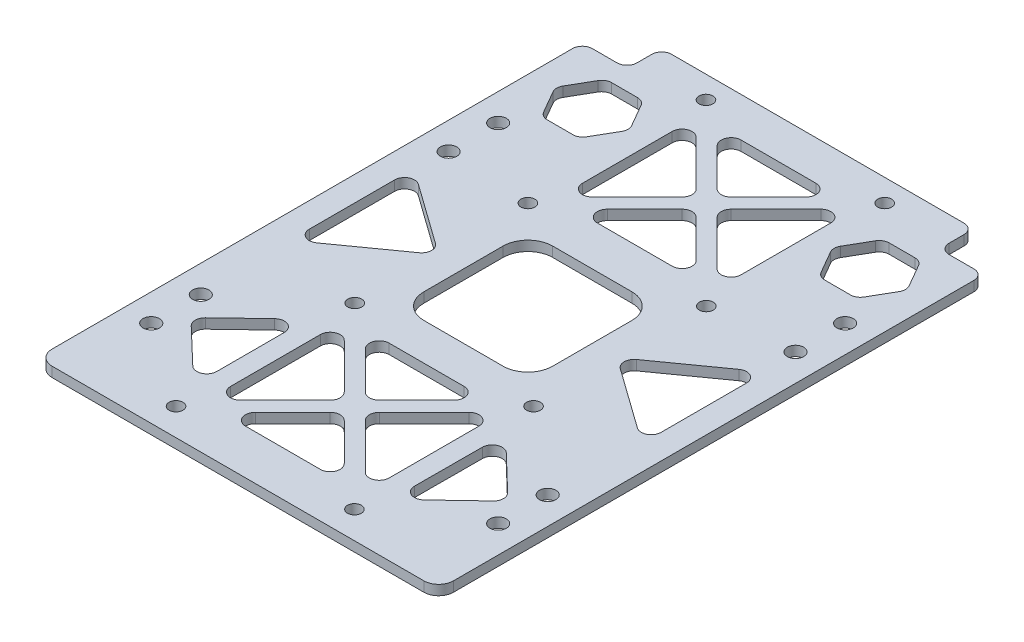
from build123d import *

# Parameters (mm, degrees)
SKETCH_1_W             = 81
SKETCH_1_H             = 117
EXTRUDE_1_DEPTH        = 2
FILLET_2_R             = 3
SKETCH_2_R             = 1.4
SKETCH_2_R_2           = 1.65
CUT_EXTRUDE_1_DEPTH    = 10
CUT_EXTRUDE_2_DEPTH    = 10
FILLET_3_R             = 2
CUT_EXTRUDE_3_DEPTH    = 10
FILLET_4_R             = 2
SKETCH_6_W             = 26
SKETCH_6_H             = 26
CUT_EXTRUDE_4_DEPTH    = 10
FILLET_5_R             = 5
CUT_EXTRUDE_5_DEPTH    = 10
FILLET_6_R             = 2
FILLET_6_OF_MIRROR_1_R = 2
CUT_EXTRUDE_6_DEPTH    = 10
CUT_EXTRUDE_7_DEPTH    = 10
FILLET_7_R             = 2


with BuildPart() as part:
    # 草图1 → 凸台-拉伸1 (new body)
    with BuildSketch(Plane(origin=(0, 0, 0), x_dir=(1, 0, 0), z_dir=(0, 1, 0))):
        Rectangle(SKETCH_1_W, SKETCH_1_H)
    extrude(amount=EXTRUDE_1_DEPTH)

    # 圆角2
    fillet_2_edges = [part.edges().sort_by_distance(p)[0] for p in [
        (40.5, 1, 58.5),
        (-40.5, 1, 58.5),
        (-40.5, 1, -58.5),
        (40.5, 1, -58.5),
    ]]
    fillet(fillet_2_edges, radius=FILLET_2_R)

    # 草图2 → 切除-拉伸1 (cut)
    with BuildSketch(Plane.XZ):
        with Locations((-18.000036, 16.931963864)):
            Circle(SKETCH_2_R)
        with Locations((18.068036136, 16.931963864)):
            Circle(SKETCH_2_R)
        with Locations((-18.000036, 53.000036)):
            Circle(SKETCH_2_R)
        with Locations((17.999928, 52.999964)):
            Circle(SKETCH_2_R)
        with Locations((-18, -18.000036)):
            Circle(SKETCH_2_R)
        with Locations((18, -18)):
            Circle(SKETCH_2_R)
        with Locations((-18.068108136, -53.999964)):
            Circle(SKETCH_2_R)
        with Locations((17.999928, -53.999964)):
            Circle(SKETCH_2_R)
        with Locations((-35, 41)):
            Circle(SKETCH_2_R_2)
        with Locations((35, 41)):
            Circle(SKETCH_2_R_2)
        with Locations((35, -19)):
            Circle(SKETCH_2_R_2)
        with Locations((-35, -19)):
            Circle(SKETCH_2_R_2)
        with Locations((-35, 31)):
            Circle(SKETCH_2_R_2)
        with Locations((-35, -29)):
            Circle(SKETCH_2_R_2)
        with Locations((35, -29)):
            Circle(SKETCH_2_R_2)
        with Locations((35, 31)):
            Circle(SKETCH_2_R_2)
    extrude(amount=-CUT_EXTRUDE_1_DEPTH, mode=Mode.SUBTRACT)

    # 草图4 → 切除-拉伸2 (cut)
    with BuildSketch(Plane.XZ):
        with BuildLine():
            Line((31.5, -58.5), (31.5, -51.5))
            Line((31.5, -51.5), (40.5, -51.5))
            Line((40.5, -51.5), (40.5, -55.5))
            ThreePointArc((40.5, -55.5), (39.621320344, -57.621320344), (37.5, -58.5))
            Line((37.5, -58.5), (31.5, -58.5))
        make_face()
        with BuildLine():
            Line((-37.5, -58.5), (-31.5, -58.5))
            Line((-31.5, -58.5), (-31.5, -51.5))
            Line((-31.5, -51.5), (-40.5, -51.5))
            Line((-40.5, -51.5), (-40.5, -55.5))
            ThreePointArc((-40.5, -55.5), (-39.621320344, -57.621320344), (-37.5, -58.5))
        make_face()
    extrude(amount=-CUT_EXTRUDE_2_DEPTH, mode=Mode.SUBTRACT)

    # 圆角3
    fillet_3_edges = [part.edges().sort_by_distance(p)[0] for p in [
        (31.5, 1, -58.5),
        (31.5, 1, -51.5),
        (40.5, 1, -51.5),
        (-40.5, 1, -51.5),
        (-31.5, 1, -51.5),
        (-31.5, 1, -58.5),
    ]]
    fillet(fillet_3_edges, radius=FILLET_3_R)

    # 草图5 → 切除-拉伸3 (cut)
    with BuildSketch(Plane.XZ):
        Polygon((-12.344679588, 49.465999932), (12.412679725, 49.465999932), (0.034000068, 37.087320275), align=None)
        Polygon((-15.965999932, 48.844679588), (-15.965999932, 21.087320275), (-2.087320275, 34.965999932), align=None)
        Polygon((16.034000068, 48.844679588), (16.034000068, 21.087320275), (2.155320412, 34.965999932), align=None)
        Polygon((12.412679725, 20.465999932), (0.034000068, 32.844679588), (-12.344679588, 20.465999932), align=None)
        Polygon((12.412679725, -21.534036068), (0.034000068, -33.912715725), (-12.344679588, -21.534036068), align=None)
        Polygon((16.034000068, -22.155356412), (2.155320412, -36.034036068), (16.034000068, -49.912715725), align=None)
        Polygon((12.412679725, -50.534036068), (0.034000068, -38.155356412), (-12.344679588, -50.534036068), align=None)
        Polygon((-2.087320275, -36.034036068), (-15.965999932, -49.912715725), (-15.965999932, -22.155356412), align=None)
    extrude(amount=-CUT_EXTRUDE_3_DEPTH, mode=Mode.SUBTRACT)

    # 圆角4
    fillet_4_edges = [part.edges().sort_by_distance(p)[0] for p in [
        (-12.344679588, 1, -21.534036068),
        (12.412679725, 1, -21.534036068),
        (0.034000068, 1, -33.912715725),
        (12.412679725, 1, 20.465999932),
        (-12.344679588, 1, 20.465999932),
        (0.034000068, 1, 32.844679588),
        (2.155320412, 1, 34.965999932),
        (16.034000068, 1, 48.844679588),
        (16.034000068, 1, 21.087320275),
        (-15.965999932, 1, 48.844679588),
        (-2.087320275, 1, 34.965999932),
        (-15.965999932, 1, 21.087320275),
        (-15.965999932, 1, -22.155356412),
        (-2.087320275, 1, -36.034036068),
        (-15.965999932, 1, -49.912715725),
        (16.034000068, 1, -22.155356412),
        (16.034000068, 1, -49.912715725),
        (2.155320412, 1, -36.034036068),
        (12.412679725, 1, -50.534036068),
        (-12.344679588, 1, -50.534036068),
        (0.034000068, 1, -38.155356412),
        (0.034000068, 1, 37.087320275),
        (-12.344679588, 1, 49.465999932),
        (12.412679725, 1, 49.465999932),
    ]]
    fillet(fillet_4_edges, radius=FILLET_4_R)

    # 草图6 → 切除-拉伸4 (cut)
    with BuildSketch(Plane.XZ):
        Rectangle(SKETCH_6_W, SKETCH_6_H)
    extrude(amount=-CUT_EXTRUDE_4_DEPTH, mode=Mode.SUBTRACT)

    # 圆角5
    fillet_5_edges = [part.edges().sort_by_distance(p)[0] for p in [
        (13, 1, 13),
        (13, 1, -13),
        (-13, 1, -13),
        (-13, 1, 13),
    ]]
    fillet(fillet_5_edges, radius=FILLET_5_R)

    # 草图7 → 切除-拉伸5 (cut)
    with BuildSketch(Plane.XZ):
        Polygon((35.5, 12.5), (35.5, -12.5), (18, 0), align=None)
    cut_extrude_5 = extrude(amount=-CUT_EXTRUDE_5_DEPTH, mode=Mode.SUBTRACT)

    # 圆角6
    fillet_6_edges = [part.edges().sort_by_distance(p)[0] for p in [
        (18, 1, 0),
        (35.5, 1, 12.5),
        (35.5, 1, -12.5),
    ]]
    fillet(fillet_6_edges, radius=FILLET_6_R)

    # 镜向1: 切除-拉伸5 across plane
    add(cut_extrude_5.mirror(Plane(origin=(0, 0, 0), x_dir=(0, 0, 1), z_dir=(1, 0, 0))), mode=Mode.SUBTRACT)

    # 圆角6 of 镜向1
    fillet_6_of_mirror_1_edges = [part.edges().sort_by_distance(p)[0] for p in [
        (-18, 1, 0),
        (-35.5, 1, 12.5),
        (-35.5, 1, -12.5),
    ]]
    fillet(fillet_6_of_mirror_1_edges, radius=FILLET_6_OF_MIRROR_1_R)

    # 草图8 → 切除-拉伸6 (cut)
    with BuildSketch(Plane.XZ):
        Polygon((-24.241669751, -34.5), (-31.74722325, -34.5), (-35.5, -41), (-31.74722325, -47.5), (-24.241669751, -47.5), (-20.488893001, -41), align=None)
        Polygon((31.74722325, -34.5), (24.241669751, -34.5), (20.488893001, -41), (24.241669751, -47.5), (31.74722325, -47.5), (35.5, -41), align=None)
    extrude(amount=-CUT_EXTRUDE_6_DEPTH, mode=Mode.SUBTRACT)

    # 草图9 → 切除-拉伸7 (cut)
    with BuildSketch(Plane.XZ):
        Polygon((-19.965999932, 47.5), (-19.965999932, 24.5), (-32, 36), align=None)
        Polygon((32.074154001, 36.105834574), (20.002229418, 47.566017579), (20.078209775, 24.566143079), align=None)
    extrude(amount=-CUT_EXTRUDE_7_DEPTH, mode=Mode.SUBTRACT)

    # 圆角7
    fillet_7_edges = [part.edges().sort_by_distance(p)[0] for p in [
        (-24.241669751, 1, -34.5),
        (-20.488893001, 1, -41),
        (-24.241669751, 1, -47.5),
        (-31.74722325, 1, -47.5),
        (-35.5, 1, -41),
        (-31.74722325, 1, -34.5),
        (31.74722325, 1, -34.5),
        (35.5, 1, -41),
        (31.74722325, 1, -47.5),
        (24.241669751, 1, -47.5),
        (20.488893001, 1, -41),
        (24.241669751, 1, -34.5),
        (-32, 1, 36),
        (-19.965999932, 1, 47.5),
        (-19.965999932, 1, 24.5),
        (32.074154001, 1, 36.105834574),
        (20.078209775, 1, 24.566143079),
        (20.002229418, 1, 47.566017579),
    ]]
    fillet(fillet_7_edges, radius=FILLET_7_R)


solid = part.part
